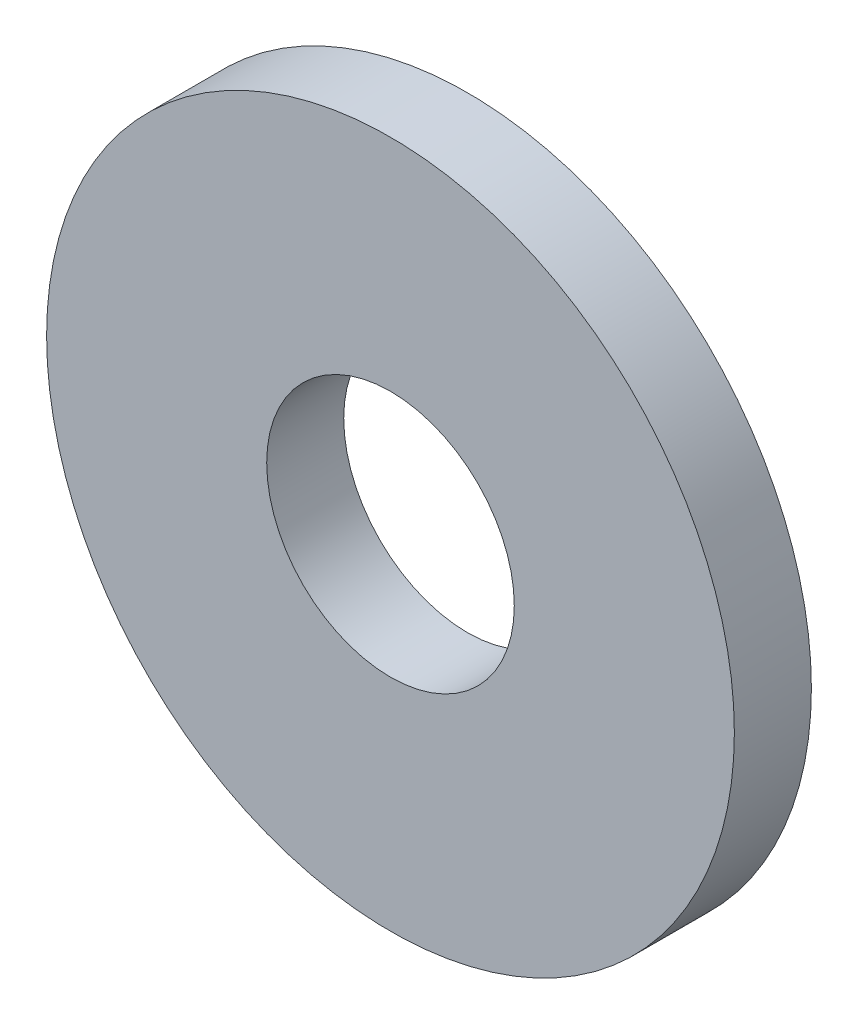
from build123d import *

# Parameters (mm, degrees)
SKETCH1_R           = 9.525
SKETCH1_R_2         = 3.429
BOSS_EXTRUDE1_DEPTH = 2.1336


with BuildPart() as part:
    # Sketch1 → Boss-Extrude1 (new body)
    with BuildSketch(Plane.XY):
        Circle(SKETCH1_R)
        Circle(SKETCH1_R_2, mode=Mode.SUBTRACT)
    extrude(amount=BOSS_EXTRUDE1_DEPTH)


solid = part.part
